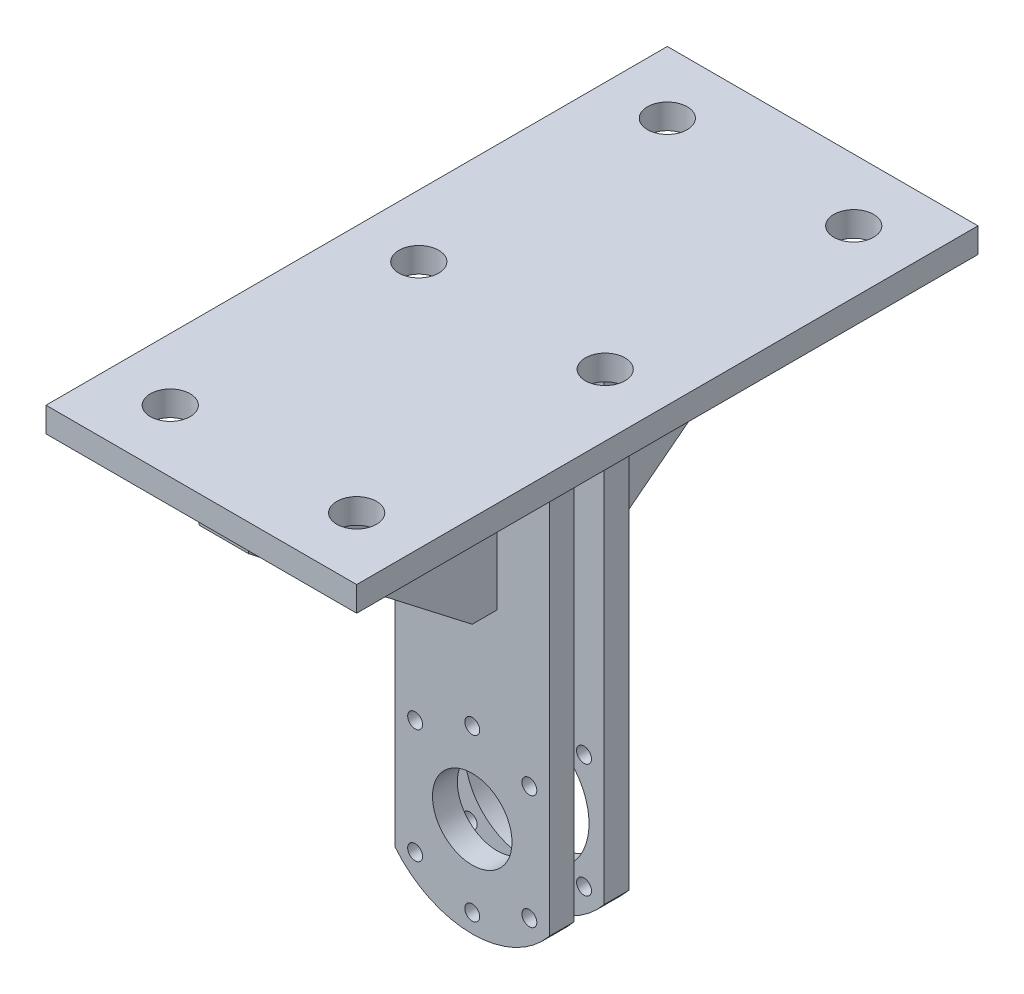
from build123d import *

# Parameters (mm, degrees)
SKETCH1_R           = 3
SKETCH1_R_2         = 16
BOSS_EXTRUDE1_DEPTH = 10
SKETCH2_R           = 3.036946437
SKETCH2_R_2         = 3
SKETCH2_R_3         = 25
BOSS_EXTRUDE2_DEPTH = 10
SKETCH3_W           = 125
SKETCH3_H           = 250
BOSS_EXTRUDE3_DEPTH = 10
BOSS_EXTRUDE4_DEPTH = 10
SKETCH6_R           = 8
CUT_EXTRUDE1_DEPTH  = 10


with BuildPart() as part:
    # Sketch1 → Boss-Extrude1 (new body)
    with BuildSketch(Plane.XY):
        with BuildLine():
            Line((-31, -25.27844932), (-31, 157.52155068))
            Line((-31, 157.52155068), (31, 157.52155068))
            Line((31, 157.52155068), (31, -25.27844932))
            ThreePointArc((31, -25.27844932), (0, -40), (-31, -25.27844932))
        make_face()
        with Locations((0, 32.5)):
            Circle(SKETCH1_R, mode=Mode.SUBTRACT)
        with Locations((-22.980970389, 22.980970389)):
            Circle(SKETCH1_R, mode=Mode.SUBTRACT)
        with Locations((22.980970389, 22.980970389)):
            Circle(SKETCH1_R, mode=Mode.SUBTRACT)
        with Locations((22.980970389, -22.980970389)):
            Circle(SKETCH1_R, mode=Mode.SUBTRACT)
        with Locations((0, -32.5)):
            Circle(SKETCH1_R, mode=Mode.SUBTRACT)
        with Locations((-22.980970389, -22.980970389)):
            Circle(SKETCH1_R, mode=Mode.SUBTRACT)
        Circle(SKETCH1_R_2, mode=Mode.SUBTRACT)
    extrude(amount=BOSS_EXTRUDE1_DEPTH)



with BuildPart() as body_2:
    # Sketch2 → Boss-Extrude2 (new body)
    with BuildSketch(Plane(origin=(0, 0, -12), x_dir=(-1, 0, 0), z_dir=(0, 0, -1))):
        with BuildLine():
            Line((-31, 157.52155068), (31, 157.52155068))
            Line((31, 157.52155068), (31, -25.27844932))
            ThreePointArc((31, -25.27844932), (0, -40), (-31, -25.27844932))
            Line((-31, -25.27844932), (-31, 157.52155068))
        make_face()
        with Locations((0, 32.5)):
            Circle(SKETCH2_R, mode=Mode.SUBTRACT)
        with Locations((22.980970389, 22.980970389)):
            Circle(SKETCH2_R_2, mode=Mode.SUBTRACT)
        with Locations((-22.980970389, 22.980970389)):
            Circle(SKETCH2_R_2, mode=Mode.SUBTRACT)
        with Locations((22.980970389, -22.980970389)):
            Circle(SKETCH2_R_2, mode=Mode.SUBTRACT)
        with Locations((0, -32.5)):
            Circle(SKETCH2_R_2, mode=Mode.SUBTRACT)
        with Locations((-22.980970389, -22.980970389)):
            Circle(SKETCH2_R_2, mode=Mode.SUBTRACT)
        Circle(SKETCH2_R_3, mode=Mode.SUBTRACT)
    extrude(amount=BOSS_EXTRUDE2_DEPTH)


with BuildPart() as part_1:
    add(part.part)

    add(body_2.part)  # Boss-Extrude3 merges body 2
    # Sketch3 → Boss-Extrude3 (add)
    with BuildSketch(Plane(origin=(0, 157.52155068, 0), x_dir=(1, 0, 0), z_dir=(0, 1, 0))):
        with Locations((0, 6)):
            Rectangle(SKETCH3_W, SKETCH3_H)
    extrude(amount=BOSS_EXTRUDE3_DEPTH)

    # Sketch5 → Boss-Extrude4 (add, symmetric)
    with BuildSketch(Plane(origin=(0, 0, 0), x_dir=(0, 0, -1), z_dir=(1, 0, 0))):
        Polygon((22, 157.52155068), (122, 157.52155068), (122, 147.52155068), (32, 77.933321793), (22, 77.933321793), align=None)
        Polygon((-20, 77.933321793), (-10, 77.933321793), (-10, 157.52155068), (-110, 157.52155068), (-110, 147.52155068), align=None)
    extrude(amount=BOSS_EXTRUDE4_DEPTH, both=True)

    # Sketch6 → Cut-Extrude1 (cut)
    with BuildSketch(Plane(origin=(0, 167.52155068, 0), x_dir=(1, 0, 0), z_dir=(0, 1, 0))):
        with Locations((-37.5, 106)):
            Circle(SKETCH6_R)
        with Locations((37.5, 106)):
            Circle(SKETCH6_R)
        with Locations((37.5, 6)):
            Circle(SKETCH6_R)
        with Locations((37.5, -94)):
            Circle(SKETCH6_R)
        with Locations((-37.5, -94)):
            Circle(SKETCH6_R)
        with Locations((-37.5, 6)):
            Circle(SKETCH6_R)
    extrude(amount=-CUT_EXTRUDE1_DEPTH, mode=Mode.SUBTRACT)


solid = part_1.part
